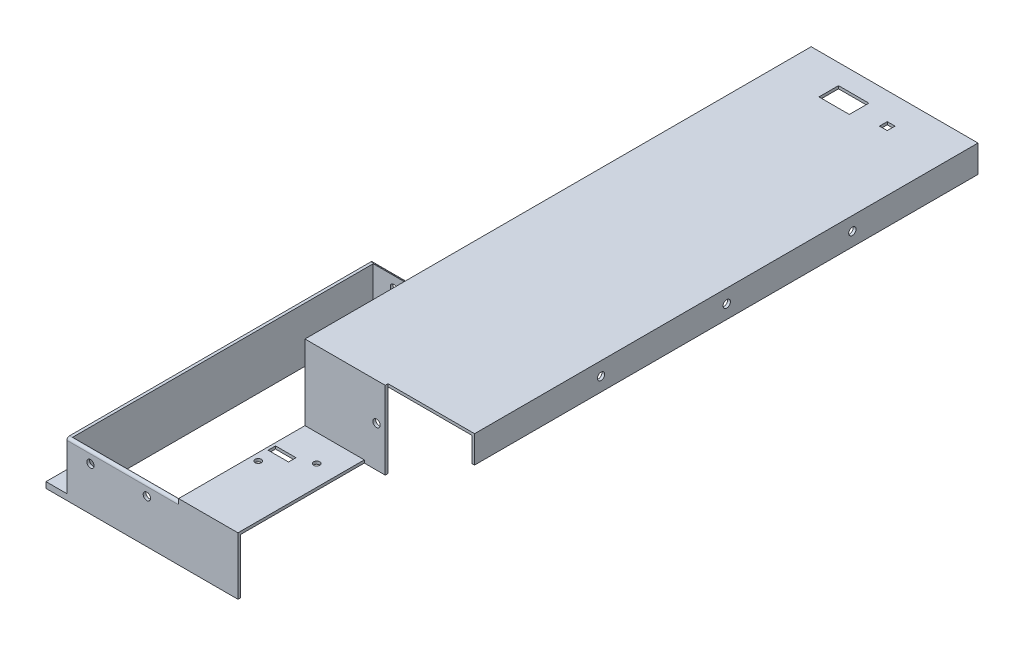
from build123d import *

# Parameters (mm, degrees)
BOSS_EXTRUDE1_DEPTH  = 76
SKETCH2_W            = 187.5
SKETCH2_H            = 42.6
CUT_EXTRUDE1_DEPTH   = 64
BOSS_EXTRUDE2_DEPTH  = 3.4
CUT_EXTRUDE2_DEPTH   = 12
SKETCH5_W            = 1.6
SKETCH5_H            = 42.6
BOSS_EXTRUDE3_DEPTH  = 141.4
SKETCH6_W            = 1.6
SKETCH6_H            = 33.4
BOSS_EXTRUDE4_DEPTH  = 158
SKETCH7_W            = 74
SKETCH7_H            = 1.6
BOSS_EXTRUDE5_DEPTH  = 94
SKETCH8_W            = 1.6
SKETCH8_H            = 41
CUT_EXTRUDE3_DEPTH   = 74
SKETCH10_W           = 95.6
SKETCH10_H           = 41
BOSS_EXTRUDE8_DEPTH  = 1.6
SKETCH11_W           = 62.4
SKETCH11_H           = 32.5
CUT_EXTRUDE4_DEPTH   = 33.4
SKETCH12_W           = 1.6
SKETCH12_H           = 32.5
CUT_EXTRUDE5_DEPTH   = 33.4
SKETCH13_W           = 61.6
SKETCH13_H           = 76
CUT_EXTRUDE6_DEPTH   = 74
SKETCH16_W           = 1.6
SKETCH16_H           = 42.6
BOSS_EXTRUDE11_DEPTH = 12
SKETCH17_W           = 288.5
SKETCH17_H           = 1.6
BOSS_EXTRUDE12_DEPTH = 94
SKETCH18_W           = 1.6
SKETCH18_H           = 288.5
BOSS_EXTRUDE13_DEPTH = 14
SKETCH19_R           = 1.75
SKETCH19_R_2         = 1.76
CUT_EXTRUDE7_DEPTH   = 5
SKETCH20_R           = 2.1
CUT_EXTRUDE9_DEPTH   = 195
SKETCH21_R           = 2.5
CUT_EXTRUDE10_DEPTH  = 10
SKETCH22_R           = 2.1
CUT_EXTRUDE11_DEPTH  = 4
SKETCH23_R           = 2.1
CUT_EXTRUDE12_DEPTH  = 4
SKETCH25_W           = 17.4
SKETCH25_H           = 11.2
SKETCH25_W_2         = 4.442640687
SKETCH25_H_2         = 4.442640687
CUT_EXTRUDE13_DEPTH  = 4
SKETCH27_W           = 64
SKETCH27_H           = 175.5
CUT_EXTRUDE15_DEPTH  = 2
CUT_EXTRUDE16_DEPTH  = 52
BOSS_EXTRUDE14_DEPTH = 2
SKETCH33_W           = 34
SKETCH33_H           = 1.6
BOSS_EXTRUDE16_DEPTH = 72.4
FILLET1_R            = 1.5
SKETCH34_R           = 1.76
SKETCH34_R_2         = 1.75
CUT_EXTRUDE17_DEPTH  = 10
SKETCH35_W           = 11.747931796
SKETCH35_H           = 4.280254221
CUT_EXTRUDE18_DEPTH  = 10


with BuildPart() as part:
    # Sketch1 → Boss-Extrude1 (new body)
    with BuildSketch(Plane(origin=(0, 0, 0), x_dir=(1, 0, 0), z_dir=(0, 1, 0))):
        Polygon((0, 0), (0, 187.5), (64, 187.5), (64, 374.5), (65.6, 374.5), (65.6, 153.4), (1.6, 153.4), (1.6, 0), align=None)
    extrude(amount=BOSS_EXTRUDE1_DEPTH)

    # Sketch2 → Cut-Extrude1 (cut)
    with BuildSketch(Plane.ZY):
        with Locations((-93.75, 54.7)):
            Rectangle(SKETCH2_W, SKETCH2_H)
    extrude(amount=-CUT_EXTRUDE1_DEPTH, mode=Mode.SUBTRACT)

    # Sketch3 → Boss-Extrude2 (add)
    with BuildSketch(Plane.XZ):
        Polygon((0, 0), (-12, 0), (-12, -199.5), (52, -199.5), (52, -374.5), (64, -374.5), (64, -187.5), (0, -187.5), align=None)
    extrude(amount=-BOSS_EXTRUDE2_DEPTH)

    # Sketch4 → Cut-Extrude2 (cut)
    with BuildSketch(Plane.XY):
        Polygon((-12, 0), (-12, 3.4), (0, 3.4), (0, 33.4), (1.6, 33.4), (1.6, 0), align=None)
    extrude(amount=-CUT_EXTRUDE2_DEPTH, mode=Mode.SUBTRACT)

    # Sketch5 → Boss-Extrude3 (add)
    with BuildSketch(Plane.XY.offset(-153.4)):
        with Locations((64.8, 54.7)):
            Rectangle(SKETCH5_W, SKETCH5_H)
    extrude(amount=BOSS_EXTRUDE3_DEPTH)

    # Sketch6 → Boss-Extrude4 (add)
    with BuildSketch(Plane(origin=(1.6, 0, 0), x_dir=(0, 0, -1), z_dir=(1, 0, 0))):
        with Locations((12.8, 16.7)):
            Rectangle(SKETCH6_W, SKETCH6_H)
    extrude(amount=BOSS_EXTRUDE4_DEPTH)

    # Sketch7 → Boss-Extrude5 (add)
    with BuildSketch(Plane(origin=(65.6, 0, 0), x_dir=(0, 0, -1), z_dir=(1, 0, 0))):
        with Locations((49, 34.2)):
            Rectangle(SKETCH7_W, SKETCH7_H)
    extrude(amount=BOSS_EXTRUDE5_DEPTH)

    # Sketch8 → Cut-Extrude3 (cut)
    with BuildSketch(Plane.XY.offset(-12)):
        with Locations((64.8, 55.5)):
            Rectangle(SKETCH8_W, SKETCH8_H)
    extrude(amount=-CUT_EXTRUDE3_DEPTH, mode=Mode.SUBTRACT)

    # Sketch10 → Boss-Extrude8 (add)
    with BuildSketch(Plane.XY.offset(-86)):
        with Locations((111.8, 55.5)):
            Rectangle(SKETCH10_W, SKETCH10_H)
    extrude(amount=BOSS_EXTRUDE8_DEPTH)

    # Sketch11 → Cut-Extrude4 (cut)
    with BuildSketch(Plane(origin=(0, 33.4, 0), x_dir=(1, 0, 0), z_dir=(0, 1, 0))):
        with Locations((32.8, 169.65)):
            Rectangle(SKETCH11_W, SKETCH11_H)
    extrude(amount=-CUT_EXTRUDE4_DEPTH, mode=Mode.SUBTRACT)

    # Sketch12 → Cut-Extrude5 (cut)
    with BuildSketch(Plane.XZ):
        with Locations((64.8, -169.65)):
            Rectangle(SKETCH12_W, SKETCH12_H)
    extrude(amount=-CUT_EXTRUDE5_DEPTH, mode=Mode.SUBTRACT)

    # Sketch13 → Cut-Extrude6 (cut)
    with BuildSketch(Plane.XY.offset(-12)):
        with Locations((128.8, 38)):
            Rectangle(SKETCH13_W, SKETCH13_H)
    extrude(amount=-CUT_EXTRUDE6_DEPTH, mode=Mode.SUBTRACT)

    # Sketch16 → Boss-Extrude11 (add)
    with BuildSketch(Plane(origin=(98, 0, 0), x_dir=(0, 0, -1), z_dir=(1, 0, 0))):
        with Locations((85.2, 54.7)):
            Rectangle(SKETCH16_W, SKETCH16_H)
    extrude(amount=BOSS_EXTRUDE11_DEPTH)

    # Sketch17 → Boss-Extrude12 (add)
    with BuildSketch(Plane(origin=(65.6, 0, 0), x_dir=(0, 0, -1), z_dir=(1, 0, 0))):
        with Locations((230.25, 75.2)):
            Rectangle(SKETCH17_W, SKETCH17_H)
    extrude(amount=BOSS_EXTRUDE12_DEPTH)

    # Sketch18 → Boss-Extrude13 (add)
    with BuildSketch(Plane.XZ.offset(-74.4)):
        with Locations((158.8, -230.25)):
            Rectangle(SKETCH18_W, SKETCH18_H)
    extrude(amount=BOSS_EXTRUDE13_DEPTH)

    # Sketch19 → Cut-Extrude7 (cut)
    with BuildSketch(Plane(origin=(0, 35, 0), x_dir=(1, 0, 0), z_dir=(0, 1, 0))):
        with Locations((68.171265028, 53.435726648)):
            Circle(SKETCH19_R)
        with Locations((86.171265028, 68.935726648)):
            Circle(SKETCH19_R_2)
    extrude(amount=-CUT_EXTRUDE7_DEPTH, mode=Mode.SUBTRACT)

    # Sketch20 → Cut-Extrude9 (cut)
    with BuildSketch(Plane(origin=(0, 0, -187.5), x_dir=(-1, 0, 0), z_dir=(0, 0, -1))):
        with Locations((-45.791182174, 25)):
            Circle(SKETCH20_R)
        with Locations((-13.491811911, 25)):
            Circle(SKETCH20_R)
    extrude(amount=-CUT_EXTRUDE9_DEPTH, mode=Mode.SUBTRACT)

    # Sketch21 → Cut-Extrude10 (cut)
    with BuildSketch(Plane(origin=(0, 3.4, 0), x_dir=(1, 0, 0), z_dir=(0, 1, 0))):
        with Locations((58, 316.5)):
            Circle(SKETCH21_R)
        with Locations((58, 258.5)):
            Circle(SKETCH21_R)
        with Locations((-6, 72)):
            Circle(SKETCH21_R)
        with Locations((-6, 132)):
            Circle(SKETCH21_R)
        with Locations((20, 194.5)):
            Circle(SKETCH21_R)
    extrude(amount=-CUT_EXTRUDE10_DEPTH, mode=Mode.SUBTRACT)

    # Sketch22 → Cut-Extrude11 (cut)
    with BuildSketch(Plane(origin=(159.6, 0, 0), x_dir=(0, 0, -1), z_dir=(1, 0, 0))):
        with Locations((302.5, 68.2)):
            Circle(SKETCH22_R)
        with Locations((230.5, 68.2)):
            Circle(SKETCH22_R)
        with Locations((158.5, 68.2)):
            Circle(SKETCH22_R)
    extrude(amount=-CUT_EXTRUDE11_DEPTH, mode=Mode.SUBTRACT)

    # Sketch23 → Cut-Extrude12 (cut)
    with BuildSketch(Plane.XY.offset(-84.4)):
        with Locations((105, 54.7)):
            Circle(SKETCH23_R)
    extrude(amount=-CUT_EXTRUDE12_DEPTH, mode=Mode.SUBTRACT)

    # Sketch25 → Cut-Extrude13 (cut)
    with BuildSketch(Plane(origin=(0, 76, 0), x_dir=(1, 0, 0), z_dir=(0, 1, 0))):
        with Locations((99.847103991, 357.413251396)):
            Rectangle(SKETCH25_W, SKETCH25_H)
        with Locations((125.211009125, 356.886739943)):
            Rectangle(SKETCH25_W_2, SKETCH25_H_2)
    extrude(amount=-CUT_EXTRUDE13_DEPTH, mode=Mode.SUBTRACT)

    # Sketch27 → Cut-Extrude15 (cut)
    with BuildSketch(Plane(origin=(0, 33.4, 0), x_dir=(1, 0, 0), z_dir=(0, 1, 0))):
        with Locations((32, 99.75)):
            Rectangle(SKETCH27_W, SKETCH27_H)
    extrude(amount=-CUT_EXTRUDE15_DEPTH, mode=Mode.SUBTRACT)

    # Sketch28 → Cut-Extrude16 (cut)
    with BuildSketch(Plane.ZY.offset(-64)):
        Polygon((-84.4, 35), (-84.4, 33.4), (-13.6, 33.4), (-13.6, 31.4), (-12, 31.4), (-12, 35), align=None)
    extrude(amount=-CUT_EXTRUDE16_DEPTH, mode=Mode.SUBTRACT)

    # Sketch29 → Boss-Extrude14 (add)
    with BuildSketch(Plane.XZ.offset(-33.4)):
        Polygon((110, -86), (110, -84.4), (64, -84.4), (64, -185.9), (65.6, -185.9), (65.6, -86), align=None)
    extrude(amount=BOSS_EXTRUDE14_DEPTH)

    # Sketch33 → Boss-Extrude16 (add)
    with BuildSketch(Plane.XY.offset(-12)):
        with Locations((81, 32.2)):
            Rectangle(SKETCH33_W, SKETCH33_H)
    extrude(amount=-BOSS_EXTRUDE16_DEPTH)

    # Fillet1
    fillet1_edges = [part.edges().sort_by_distance(p)[0] for p in [
        (32, 31.4, -187.5),
        (32, 31.4, -12),
    ]]
    fillet(fillet1_edges, radius=FILLET1_R)

    # Sketch34 → Cut-Extrude17 (cut)
    with BuildSketch(Plane(origin=(0, 33, 0), x_dir=(1, 0, 0), z_dir=(0, 1, 0))):
        with Locations((86.171265028, 68.935726648)):
            Circle(SKETCH34_R)
        with Locations((68.171265028, 53.435726648)):
            Circle(SKETCH34_R_2)
    extrude(amount=-CUT_EXTRUDE17_DEPTH, mode=Mode.SUBTRACT)

    # Sketch35 → Cut-Extrude18 (cut)
    with BuildSketch(Plane(origin=(0, 33, 0), x_dir=(1, 0, 0), z_dir=(0, 1, 0))):
        with Locations((71.491311388, 63.76994517)):
            Rectangle(SKETCH35_W, SKETCH35_H)
    extrude(amount=-CUT_EXTRUDE18_DEPTH, mode=Mode.SUBTRACT)


solid = part.part
